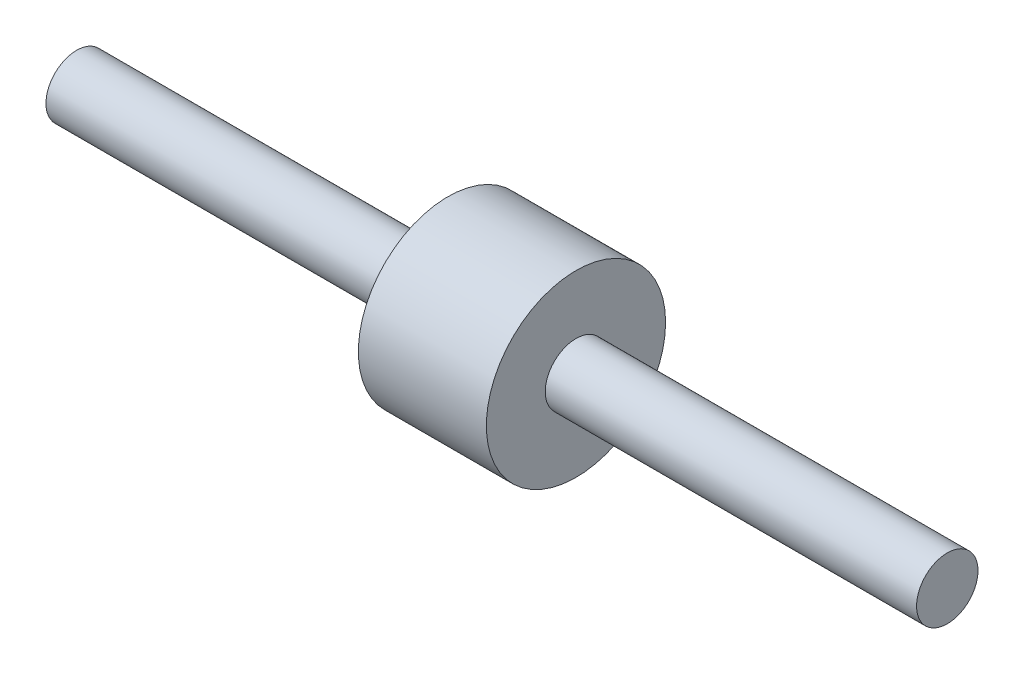
from build123d import *

# Parameters (mm, degrees)
CROQUIS1_R              = 17.5
SALIENTE_EXTRUIR1_DEPTH = 12.5
CROQUIS2_R              = 6
SALIENTE_EXTRUIR2_DEPTH = 72.5


with BuildPart() as part:
    # Croquis1 → Saliente-Extruir1 (new body, symmetric)
    with BuildSketch(Plane(origin=(0, 0, 0), x_dir=(0, 0, -1), z_dir=(1, 0, 0))):
        Circle(CROQUIS1_R)
    extrude(amount=SALIENTE_EXTRUIR1_DEPTH, both=True)

    # Croquis2 → Saliente-Extruir2 (add)
    with BuildSketch(Plane(origin=(12.5, 0, 0), x_dir=(0, 0, -1), z_dir=(1, 0, 0))):
        Circle(CROQUIS2_R)
    saliente_extruir2 = extrude(amount=SALIENTE_EXTRUIR2_DEPTH)

    # Simetría1: Saliente-Extruir2 across plane
    add(saliente_extruir2.mirror(Plane(origin=(0, 0, 0), x_dir=(0, 0, 1), z_dir=(1, 0, 0))))


solid = part.part
